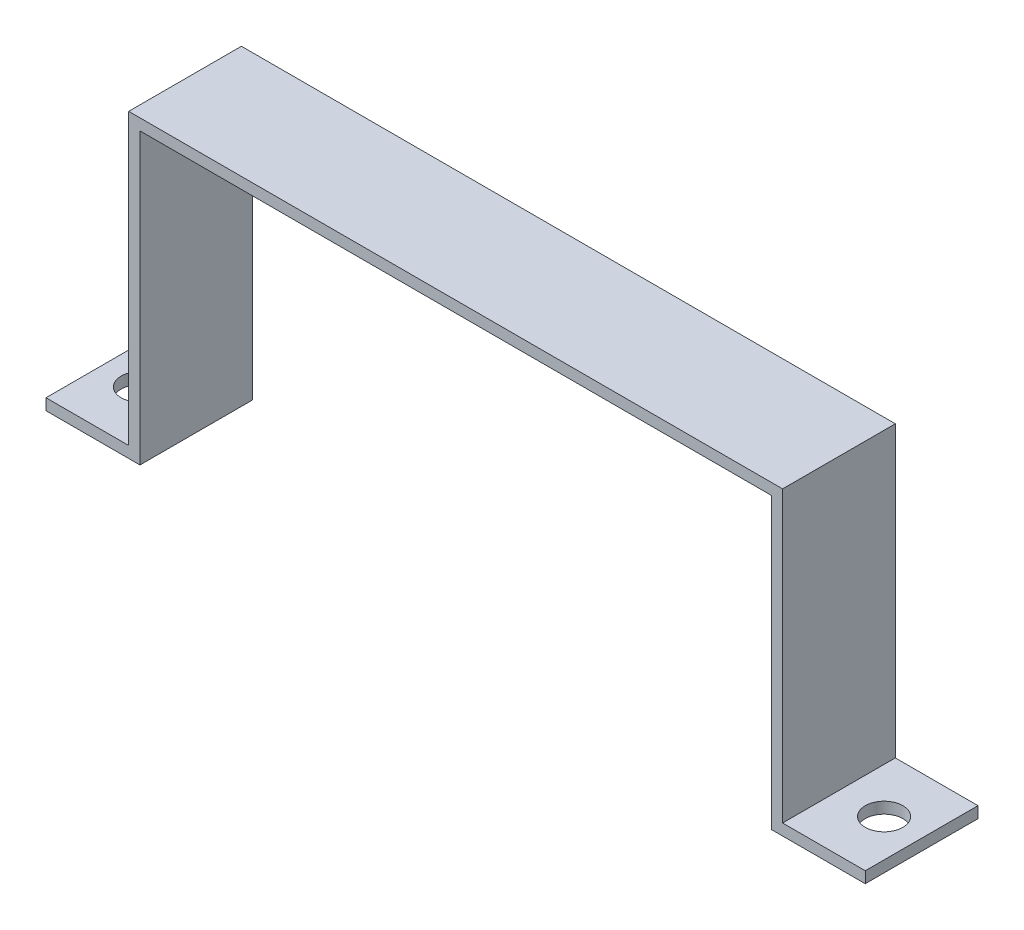
from build123d import *

# Parameters (mm, degrees)
BOSS_EXTRUDE1_DEPTH = 30
SKETCH2_R           = 5
CUT_EXTRUDE1_DEPTH  = 30


with BuildPart() as part:
    # Sketch1 → Boss-Extrude1 (new body)
    with BuildSketch(Plane.XY):
        Polygon((-84, 0), (-84, 77), (84, 77), (84, 0), (109, 0), (109, 3), (87, 3), (87, 80), (-87, 80), (-87, 3), (-109, 3), (-109, 0), align=None)
    extrude(amount=BOSS_EXTRUDE1_DEPTH)

    # Sketch2 → Cut-Extrude1 (cut)
    with BuildSketch(Plane(origin=(0, 3, 0), x_dir=(1, 0, 0), z_dir=(0, 1, 0))):
        with Locations((-99, -15)):
            Circle(SKETCH2_R)
        with Locations((99, -15)):
            Circle(SKETCH2_R)
    extrude(amount=-CUT_EXTRUDE1_DEPTH, mode=Mode.SUBTRACT)


solid = part.part
